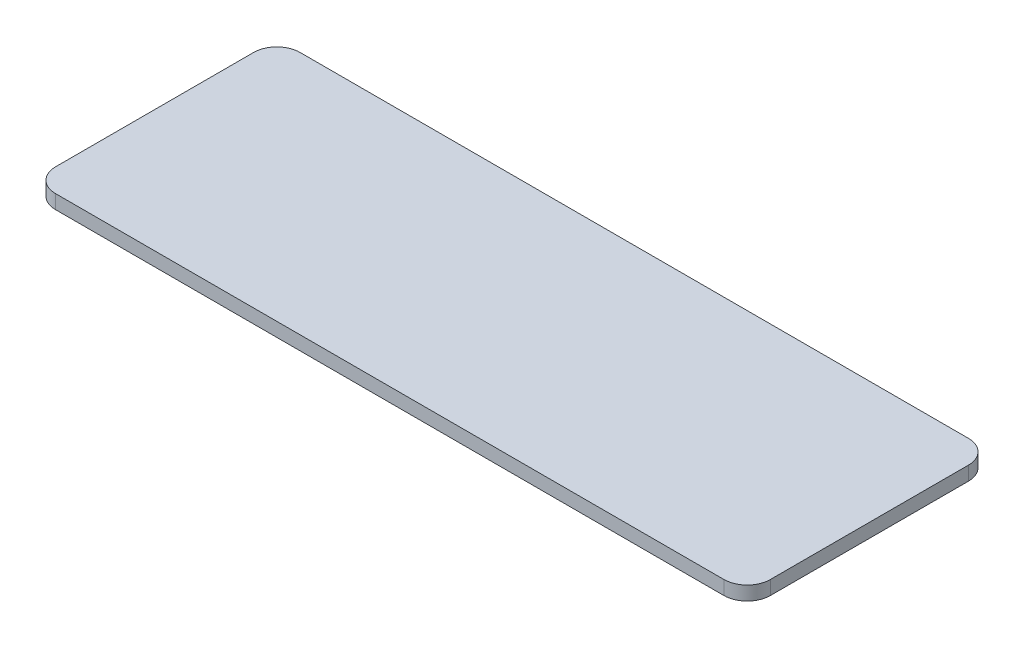
from build123d import *

# Parameters (mm, degrees)
EXTRUDE_1_DEPTH = 1.5


with BuildPart() as part:
    # 草图1 → 凸台-拉伸1 (new body)
    with BuildSketch(Plane(origin=(0, 0, 0), x_dir=(1, 0, 0), z_dir=(0, 1, 0))):
        with BuildLine():
            Line((-36, -13.17), (36, -13.17))
            ThreePointArc((36, -13.17), (37.767766953, -12.437766953), (38.5, -10.67))
            Line((38.5, -10.67), (38.5, 10.67))
            ThreePointArc((38.5, 10.67), (37.767766953, 12.437766953), (36, 13.17))
            Line((36, 13.17), (-36, 13.17))
            ThreePointArc((-36, 13.17), (-37.767766953, 12.437766953), (-38.5, 10.67))
            Line((-38.5, 10.67), (-38.5, -10.67))
            ThreePointArc((-38.5, -10.67), (-37.767766953, -12.437766953), (-36, -13.17))
        make_face()
    extrude(amount=EXTRUDE_1_DEPTH)


solid = part.part
